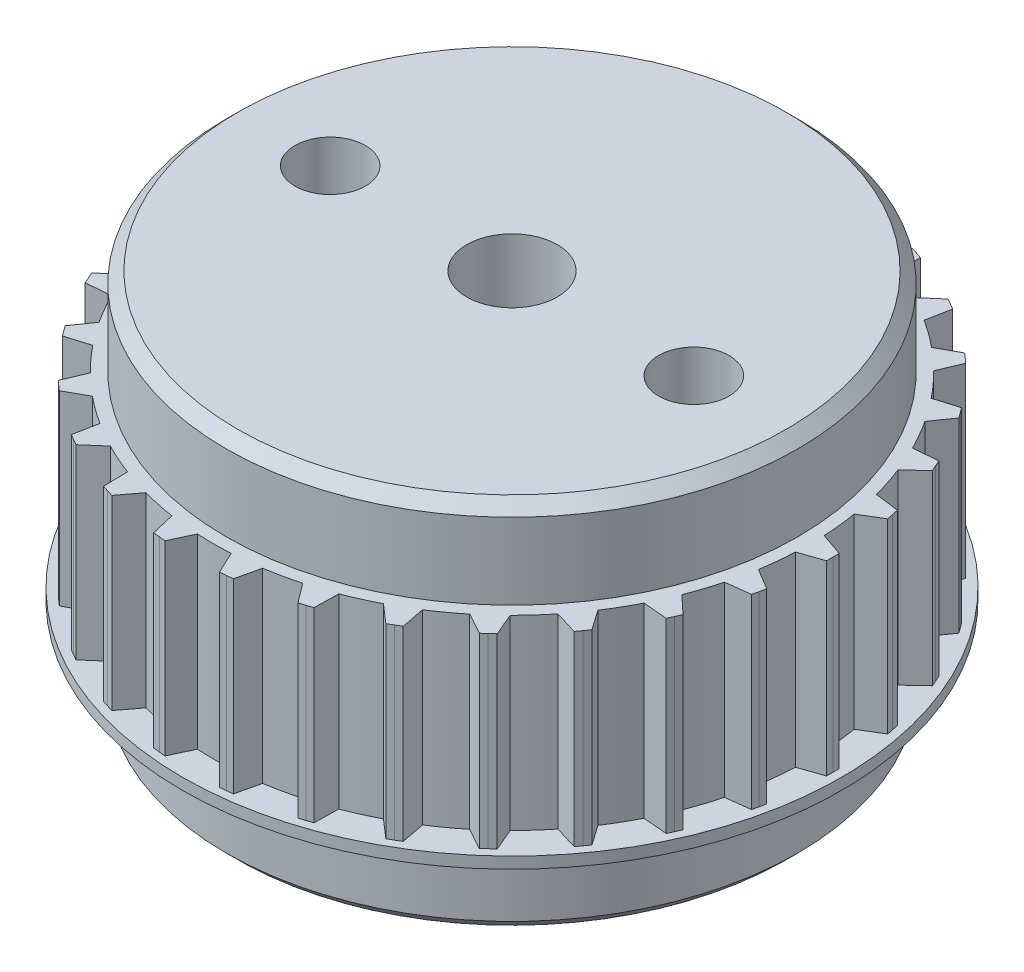
from build123d import *

# Parameters (mm, degrees)
SKETCH3_R               = 13.12
BOSS_EXTRUDE1_DEPTH     = 8.2
BOSS_EXTRUDE2_DEPTH     = 8.2
SKETCH5_R               = 14.5
BOSS_EXTRUDE3_DEPTH     = 0.5
SKETCH6_R               = 12.575
BOSS_EXTRUDE4_DEPTH     = 3.85
SKETCH7_R               = 12.575
BOSS_EXTRUDE5_DEPTH     = 3.85
CHAMFER1_SIZE           = 0.5
SKETCH8_W               = 10
SKETCH8_H               = 18
CUT_EXTRUDE1_DEPTH      = 1
CUT_EXTRUDE1_DEPTH_BACK = 17.4
SKETCH9_R               = 1.55
CUT_EXTRUDE2_DEPTH      = 1
CUT_EXTRUDE2_DEPTH_BACK = 17.4
FILLET1_R               = 1
SKETCH10_W              = 12.014676896
SKETCH10_H              = 19.313916084
SKETCH10_R              = 1.995
BOSS_EXTRUDE6_DEPTH     = 16.4


with BuildPart() as part:
    # Sketch3 → Boss-Extrude1 (new body)
    with BuildSketch(Plane(origin=(0, 0, 0), x_dir=(1, 0, 0), z_dir=(0, 1, 0))):
        Circle(SKETCH3_R)
    extrude(amount=BOSS_EXTRUDE1_DEPTH)

    # Sketch4 → Boss-Extrude2 (add)
    with BuildSketch(Plane(origin=(0, 0, 0), x_dir=(1, 0, 0), z_dir=(0, 1, 0))):
        with BuildLine():
            Line((-14.117223523, -0.28), (-12.849948906, -0.718131678))
            ThreePointArc((-12.849948906, -0.718131678), (-12.87, 1.758e-06), (-12.84994871, 0.718135188))
            Line((-12.84994871, 0.718135188), (-14.117223796, 0.279986237))
            Line((-14.117223796, 0.279986237), (-14.12, 0))
            Line((-14.12, 0), (-14.117223523, -0.28))
        make_face()
        with BuildLine():
            Line((-13.866943592, 2.661254484), (-12.718454664, 1.969215826))
            ThreePointArc((-12.718454664, 1.969215826), (-12.588759256, 2.67582518), (-12.419837799, 3.374096774))
            Line((-12.419837799, 3.374096774), (-13.750516173, 3.209003735))
            Line((-13.750516173, 3.209003735), (-13.811444122, 2.935713074))
            Line((-13.811444122, 2.935713074), (-13.866943592, 2.661254484))
        make_face()
        with BuildLine():
            Line((-13.010611684, 5.486199377), (-12.031102922, 4.570499149))
            ThreePointArc((-12.031102922, 4.570499149), (-11.757329325, 5.234702202), (-11.446920379, 5.882594141))
            Line((-11.446920379, 5.882594141), (-12.782845011, 5.997772371))
            Line((-12.782845011, 5.997772371), (-12.899261862, 5.7431214))
            Line((-12.899261862, 5.7431214), (-13.010611684, 5.486199377))
        make_face()
        with BuildLine():
            Line((-11.585653614, 8.071371032), (-10.817934252, 6.972029728))
            ThreePointArc((-10.817934252, 6.972029728), (-10.412047685, 7.564797619), (-9.973717611, 8.133993916))
            Line((-9.973717611, 8.133993916), (-11.256502184, 8.524409574))
            Line((-11.256502184, 8.524409574), (-11.423319961, 8.299527762))
            Line((-11.423319961, 8.299527762), (-11.585653614, 8.071371032))
        make_face()
        with BuildLine():
            Line((-9.654346887, 10.303785041), (-9.131969944, 9.068849152))
            ThreePointArc((-9.131969944, 9.068849152), (-8.611709598, 9.56427508), (-8.064615523, 10.029899125))
            Line((-8.064615523, 10.029899125), (-9.238196196, 10.678489174))
            Line((-9.238196196, 10.678489174), (-9.448124162, 10.493204936))
            Line((-9.448124162, 10.493204936), (-9.654346887, 10.303785041))
        make_face()
        with BuildLine():
            Line((-7.301098875, 12.085874202), (-7.04689473, 10.769316351))
            ThreePointArc((-7.04689473, 10.769316351), (-6.434998478, 11.145747826), (-5.803051039, 11.487449614))
            Line((-5.803051039, 11.487449614), (-6.816136704, 12.365867557))
            Line((-6.816136704, 12.365867557), (-7.06, 12.228278701))
            Line((-7.06, 12.228278701), (-7.301098875, 12.085874202))
        make_face()
        with BuildLine():
            Line((-4.628757807, 13.339752665), (-4.653836401, 11.999112749))
            ThreePointArc((-4.653836401, 11.999112749), (-3.977047046, 12.240097908), (-3.287865378, 12.442943432))
            Line((-3.287865378, 12.442943432), (-4.096179332, 13.512798189))
            Line((-4.096179332, 13.512798189), (-4.363319961, 13.42891801))
            Line((-4.363319961, 13.42891801), (-4.628757807, 13.339752665))
        make_face()
        with BuildLine():
            Line((-1.754117811, 14.010619926), (-2.05738309, 12.704490341))
            ThreePointArc((-2.05738309, 12.704490341), (-1.345279574, 12.799496977), (-0.628984223, 12.854620914))
            Line((-0.628984223, 12.854620914), (-1.197199266, 14.069154698))
            Line((-1.197199266, 14.069154698), (-1.475941901, 14.042649163))
            Line((-1.475941901, 14.042649163), (-1.754117811, 14.010619926))
        make_face()
        with BuildLine():
            Line((1.19718555, 14.069155865), (0.628987734, 12.854620742))
            ThreePointArc((0.628987734, 12.854620742), (1.34528307, 12.79949661), (2.05738656, 12.704489779))
            Line((2.05738656, 12.704489779), (1.754104152, 14.010621636))
            Line((1.754104152, 14.010621636), (1.475941901, 14.042649163))
            Line((1.475941901, 14.042649163), (1.19718555, 14.069155865))
        make_face()
        with BuildLine():
            Line((4.096166157, 13.512802182), (3.287868777, 12.442942534))
            ThreePointArc((3.287868777, 12.442942534), (3.977050389, 12.240096822), (4.653839678, 11.999111477))
            Line((4.653839678, 11.999111477), (4.628744801, 13.339757178))
            Line((4.628744801, 13.339757178), (4.363319961, 13.42891801))
            Line((4.363319961, 13.42891801), (4.096166157, 13.512802182))
        make_face()
        with BuildLine():
            Line((6.816124648, 12.365874202), (5.803054176, 11.487448029))
            ThreePointArc((5.803054176, 11.487448029), (6.435001522, 11.145746068), (7.046897671, 10.769314426))
            Line((7.046897671, 10.769314426), (7.301087092, 12.08588132))
            Line((7.301087092, 12.08588132), (7.06, 12.228278701))
            Line((7.06, 12.228278701), (6.816124648, 12.365874202))
        make_face()
        with BuildLine():
            Line((9.238185785, 10.678498181), (8.064618263, 10.029896923))
            ThreePointArc((8.064618263, 10.029896923), (8.61171221, 9.564272728), (9.131972421, 9.068846658))
            Line((9.131972421, 9.068846658), (9.654336842, 10.303794454))
            Line((9.654336842, 10.303794454), (9.448124162, 10.493204936))
            Line((9.448124162, 10.493204936), (9.238185785, 10.678498181))
        make_face()
        with BuildLine():
            Line((11.256493873, 8.524420549), (9.973719832, 8.133991192))
            ThreePointArc((9.973719832, 8.133991192), (10.412049751, 7.564794775), (10.817936156, 6.972026773))
            Line((10.817936156, 6.972026773), (11.585645745, 8.071382327))
            Line((11.585645745, 8.071382327), (11.423319961, 8.299527762))
            Line((11.423319961, 8.299527762), (11.256493873, 8.524420549))
        make_face()
        with BuildLine():
            Line((12.782839164, 5.997784833), (11.446921986, 5.882591015))
            ThreePointArc((11.446921986, 5.882591015), (11.757330755, 5.234698991), (12.031104171, 4.570495863))
            Line((12.031104171, 4.570495863), (13.010606335, 5.486212062))
            Line((13.010606335, 5.486212062), (12.899261862, 5.7431214))
            Line((12.899261862, 5.7431214), (12.782839164, 5.997784833))
        make_face()
        with BuildLine():
            Line((13.750513045, 3.209017141), (12.419838721, 3.374093382))
            ThreePointArc((12.419838721, 3.374093382), (12.588759987, 2.675821742), (12.718455201, 1.969212352))
            Line((12.718455201, 1.969212352), (13.866940997, 2.661268004))
            Line((13.866940997, 2.661268004), (13.811444122, 2.935713074))
            Line((13.811444122, 2.935713074), (13.750513045, 3.209017141))
        make_face()
        with BuildLine():
            Line((14.117223523, 0.28), (12.849948906, 0.718131678))
            ThreePointArc((12.849948906, 0.718131678), (12.87, -1.758e-06), (12.84994871, -0.718135188))
            Line((12.84994871, -0.718135188), (14.117223796, -0.279986237))
            Line((14.117223796, -0.279986237), (14.12, 0))
            Line((14.12, 0), (14.117223523, 0.28))
        make_face()
        with BuildLine():
            Line((13.866943592, -2.661254484), (12.718454664, -1.969215826))
            ThreePointArc((12.718454664, -1.969215826), (12.588759256, -2.67582518), (12.419837799, -3.374096774))
            Line((12.419837799, -3.374096774), (13.750516173, -3.209003735))
            Line((13.750516173, -3.209003735), (13.811444122, -2.935713074))
            Line((13.811444122, -2.935713074), (13.866943592, -2.661254484))
        make_face()
        with BuildLine():
            Line((13.010611684, -5.486199377), (12.031102922, -4.570499149))
            ThreePointArc((12.031102922, -4.570499149), (11.757329325, -5.234702202), (11.446920379, -5.882594141))
            Line((11.446920379, -5.882594141), (12.782845011, -5.997772371))
            Line((12.782845011, -5.997772371), (12.899261862, -5.7431214))
            Line((12.899261862, -5.7431214), (13.010611684, -5.486199377))
        make_face()
        with BuildLine():
            Line((11.585653614, -8.071371032), (10.817934252, -6.972029728))
            ThreePointArc((10.817934252, -6.972029728), (10.412047685, -7.564797619), (9.973717611, -8.133993916))
            Line((9.973717611, -8.133993916), (11.256502184, -8.524409574))
            Line((11.256502184, -8.524409574), (11.423319961, -8.299527762))
            Line((11.423319961, -8.299527762), (11.585653614, -8.071371032))
        make_face()
        with BuildLine():
            Line((9.654346887, -10.303785041), (9.131969944, -9.068849152))
            ThreePointArc((9.131969944, -9.068849152), (8.611709598, -9.56427508), (8.064615523, -10.029899125))
            Line((8.064615523, -10.029899125), (9.238196196, -10.678489174))
            Line((9.238196196, -10.678489174), (9.448124162, -10.493204936))
            Line((9.448124162, -10.493204936), (9.654346887, -10.303785041))
        make_face()
        with BuildLine():
            Line((7.301098875, -12.085874202), (7.04689473, -10.769316351))
            ThreePointArc((7.04689473, -10.769316351), (6.434998478, -11.145747826), (5.803051039, -11.487449614))
            Line((5.803051039, -11.487449614), (6.816136704, -12.365867557))
            Line((6.816136704, -12.365867557), (7.06, -12.228278701))
            Line((7.06, -12.228278701), (7.301098875, -12.085874202))
        make_face()
        with BuildLine():
            Line((4.628757807, -13.339752665), (4.653836401, -11.999112749))
            ThreePointArc((4.653836401, -11.999112749), (3.977047046, -12.240097908), (3.287865378, -12.442943432))
            Line((3.287865378, -12.442943432), (4.096179332, -13.512798189))
            Line((4.096179332, -13.512798189), (4.363319961, -13.42891801))
            Line((4.363319961, -13.42891801), (4.628757807, -13.339752665))
        make_face()
        with BuildLine():
            Line((1.754117811, -14.010619926), (2.05738309, -12.704490341))
            ThreePointArc((2.05738309, -12.704490341), (1.345279574, -12.799496977), (0.628984223, -12.854620914))
            Line((0.628984223, -12.854620914), (1.197199266, -14.069154698))
            Line((1.197199266, -14.069154698), (1.475941901, -14.042649163))
            Line((1.475941901, -14.042649163), (1.754117811, -14.010619926))
        make_face()
        with BuildLine():
            Line((-1.19718555, -14.069155865), (-0.628987734, -12.854620742))
            ThreePointArc((-0.628987734, -12.854620742), (-1.34528307, -12.79949661), (-2.05738656, -12.704489779))
            Line((-2.05738656, -12.704489779), (-1.754104152, -14.010621636))
            Line((-1.754104152, -14.010621636), (-1.475941901, -14.042649163))
            Line((-1.475941901, -14.042649163), (-1.19718555, -14.069155865))
        make_face()
        with BuildLine():
            Line((-4.096166157, -13.512802182), (-3.287868777, -12.442942534))
            ThreePointArc((-3.287868777, -12.442942534), (-3.977050389, -12.240096822), (-4.653839678, -11.999111477))
            Line((-4.653839678, -11.999111477), (-4.628744801, -13.339757178))
            Line((-4.628744801, -13.339757178), (-4.363319961, -13.42891801))
            Line((-4.363319961, -13.42891801), (-4.096166157, -13.512802182))
        make_face()
        with BuildLine():
            Line((-6.816124648, -12.365874202), (-5.803054176, -11.487448029))
            ThreePointArc((-5.803054176, -11.487448029), (-6.435001522, -11.145746068), (-7.046897671, -10.769314426))
            Line((-7.046897671, -10.769314426), (-7.301087092, -12.08588132))
            Line((-7.301087092, -12.08588132), (-7.06, -12.228278701))
            Line((-7.06, -12.228278701), (-6.816124648, -12.365874202))
        make_face()
        with BuildLine():
            Line((-9.238185785, -10.678498181), (-8.064618263, -10.029896923))
            ThreePointArc((-8.064618263, -10.029896923), (-8.61171221, -9.564272728), (-9.131972421, -9.068846658))
            Line((-9.131972421, -9.068846658), (-9.654336842, -10.303794454))
            Line((-9.654336842, -10.303794454), (-9.448124162, -10.493204936))
            Line((-9.448124162, -10.493204936), (-9.238185785, -10.678498181))
        make_face()
        with BuildLine():
            Line((-11.256493873, -8.524420549), (-9.973719832, -8.133991192))
            ThreePointArc((-9.973719832, -8.133991192), (-10.412049751, -7.564794775), (-10.817936156, -6.972026773))
            Line((-10.817936156, -6.972026773), (-11.585645745, -8.071382327))
            Line((-11.585645745, -8.071382327), (-11.423319961, -8.299527762))
            Line((-11.423319961, -8.299527762), (-11.256493873, -8.524420549))
        make_face()
        with BuildLine():
            Line((-12.782839164, -5.997784833), (-11.446921986, -5.882591015))
            ThreePointArc((-11.446921986, -5.882591015), (-11.757330755, -5.234698991), (-12.031104171, -4.570495863))
            Line((-12.031104171, -4.570495863), (-13.010606335, -5.486212062))
            Line((-13.010606335, -5.486212062), (-12.899261862, -5.7431214))
            Line((-12.899261862, -5.7431214), (-12.782839164, -5.997784833))
        make_face()
        with BuildLine():
            Line((-13.750513045, -3.209017141), (-12.419838721, -3.374093382))
            ThreePointArc((-12.419838721, -3.374093382), (-12.588759987, -2.675821742), (-12.718455201, -1.969212352))
            Line((-12.718455201, -1.969212352), (-13.866940997, -2.661268004))
            Line((-13.866940997, -2.661268004), (-13.811444122, -2.935713074))
            Line((-13.811444122, -2.935713074), (-13.750513045, -3.209017141))
        make_face()
    extrude(amount=BOSS_EXTRUDE2_DEPTH)

    # Sketch5 → Boss-Extrude3 (add)
    with BuildSketch(Plane.XZ):
        Circle(SKETCH5_R)
    extrude(amount=BOSS_EXTRUDE3_DEPTH)

    # Sketch6 → Boss-Extrude4 (add)
    with BuildSketch(Plane(origin=(0, -0.5, 0), x_dir=(-1, 0, 0), z_dir=(0, -1, 0))):
        Circle(SKETCH6_R)
    extrude(amount=BOSS_EXTRUDE4_DEPTH)

    # Sketch7 → Boss-Extrude5 (add)
    with BuildSketch(Plane(origin=(0, 8.2, 0), x_dir=(1, 0, 0), z_dir=(0, 1, 0))):
        Circle(SKETCH7_R)
    extrude(amount=BOSS_EXTRUDE5_DEPTH)

    # Chamfer1
    chamfer1_edges = [part.edges().sort_by_distance(p)[0] for p in [
        (12.575, -4.35, 0),
        (-12.575, 12.05, 0),
    ]]
    chamfer(chamfer1_edges, length=CHAMFER1_SIZE)

    # Sketch8 → Cut-Extrude1 (cut, two sides)
    with BuildSketch(Plane(origin=(0, 12.05, 0), x_dir=(1, 0, 0), z_dir=(0, 1, 0))) as cut_extrude1_sk:
        Rectangle(SKETCH8_W, SKETCH8_H)
    extrude(amount=CUT_EXTRUDE1_DEPTH, mode=Mode.SUBTRACT)
    extrude(cut_extrude1_sk.sketch, amount=-CUT_EXTRUDE1_DEPTH_BACK, mode=Mode.SUBTRACT)

    # Sketch9 → Cut-Extrude2 (cut, two sides)
    with BuildSketch(Plane(origin=(0, 12.05, 0), x_dir=(1, 0, 0), z_dir=(0, 1, 0))) as cut_extrude2_sk:
        with Locations((-8, 0)):
            Circle(SKETCH9_R)
        with Locations((8, 0)):
            Circle(SKETCH9_R)
    extrude(amount=CUT_EXTRUDE2_DEPTH, mode=Mode.SUBTRACT)
    extrude(cut_extrude2_sk.sketch, amount=-CUT_EXTRUDE2_DEPTH_BACK, mode=Mode.SUBTRACT)

    # Fillet1
    fillet1_edges = [part.edges().sort_by_distance(p)[0] for p in [
        (-5, 3.85, 9),
        (-5, 3.85, -9),
        (5, 3.85, -9),
        (5, 3.85, 9),
    ]]
    fillet(fillet1_edges, radius=FILLET1_R)

    # Sketch10 → Boss-Extrude6 (add)
    with BuildSketch(Plane.XZ.offset(4.35)):
        Rectangle(SKETCH10_W, SKETCH10_H)
        Circle(SKETCH10_R, mode=Mode.SUBTRACT)
    extrude(amount=-BOSS_EXTRUDE6_DEPTH)


solid = part.part
